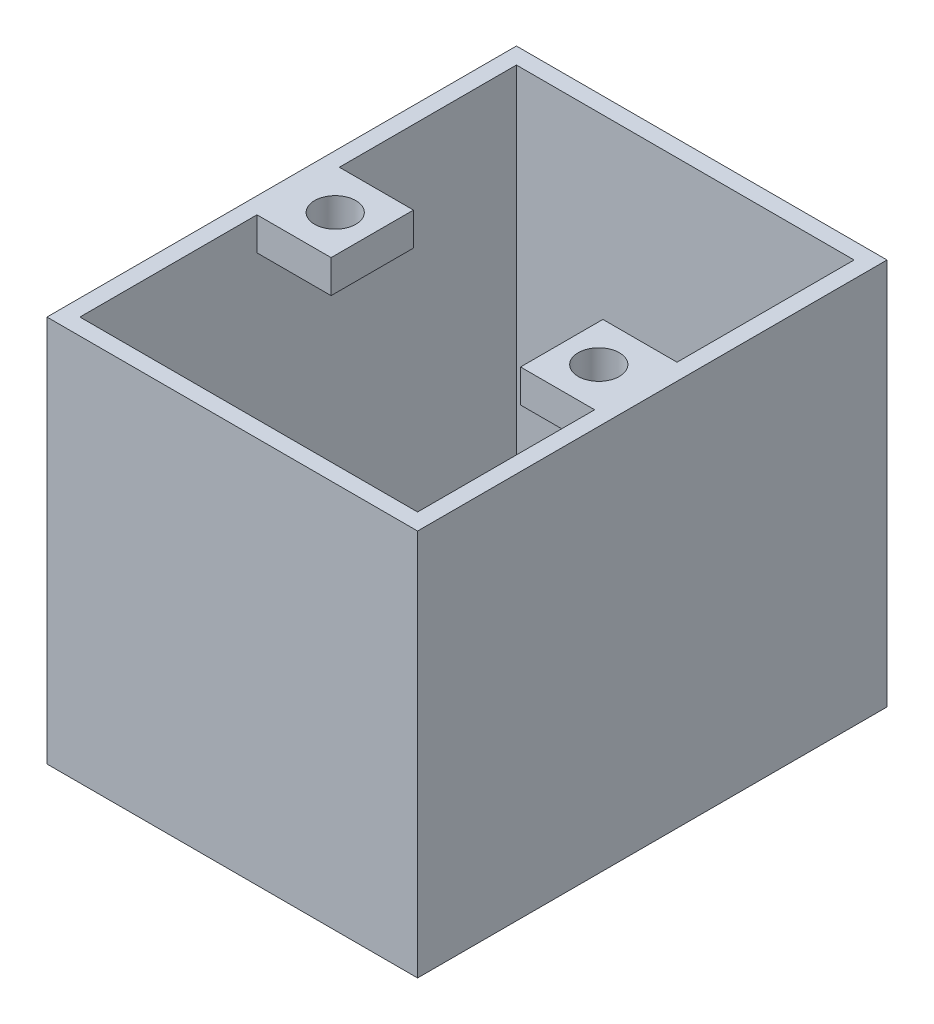
from build123d import *

# Parameters (mm, degrees)
ESQUISSE1_W        = 45
ESQUISSE1_H        = 57
ESQUISSE1_W_2      = 23
ESQUISSE1_H_2      = 43
BOSS_EXTRU_1_DEPTH = 2
ESQUISSE2_W        = 45
ESQUISSE2_H        = 57
ESQUISSE2_W_2      = 41
ESQUISSE2_H_2      = 53
BOSS_EXTRU_2_DEPTH = 45
ESQUISSE3_W        = 9
ESQUISSE3_H        = 10
ESQUISSE3_R        = 2.5
BOSS_EXTRU_3_DEPTH = 4


with BuildPart() as part:
    # Esquisse1 → Boss.-Extru.1 (new body)
    with BuildSketch(Plane(origin=(0, 0, 0), x_dir=(1, 0, 0), z_dir=(0, 1, 0))):
        with Locations((11.5, 21.5)):
            Rectangle(ESQUISSE1_W, ESQUISSE1_H)
        with Locations((11.5, 21.5)):
            Rectangle(ESQUISSE1_W_2, ESQUISSE1_H_2, mode=Mode.SUBTRACT)
    extrude(amount=BOSS_EXTRU_1_DEPTH)

    # Esquisse2 → Boss.-Extru.2 (add)
    with BuildSketch(Plane(origin=(0, 2, 0), x_dir=(1, 0, 0), z_dir=(0, 1, 0))):
        with Locations((11.5, 21.5)):
            Rectangle(ESQUISSE2_W, ESQUISSE2_H)
        with Locations((11.5, 21.5)):
            Rectangle(ESQUISSE2_W_2, ESQUISSE2_H_2, mode=Mode.SUBTRACT)
    extrude(amount=BOSS_EXTRU_2_DEPTH)

    # Esquisse3 → Boss.-Extru.3 (add)
    with BuildSketch(Plane(origin=(0, 47, 0), x_dir=(1, 0, 0), z_dir=(0, 1, 0))):
        with Locations((-4.5, 21.5)):
            Rectangle(ESQUISSE3_W, ESQUISSE3_H)
        with Locations((-4.5, 21.5)):
            Circle(ESQUISSE3_R, mode=Mode.SUBTRACT)
        with Locations((27.5, 21.5)):
            Rectangle(ESQUISSE3_W, ESQUISSE3_H)
        with Locations((27.5, 21.5)):
            Circle(ESQUISSE3_R, mode=Mode.SUBTRACT)
    extrude(amount=-BOSS_EXTRU_3_DEPTH)


solid = part.part
